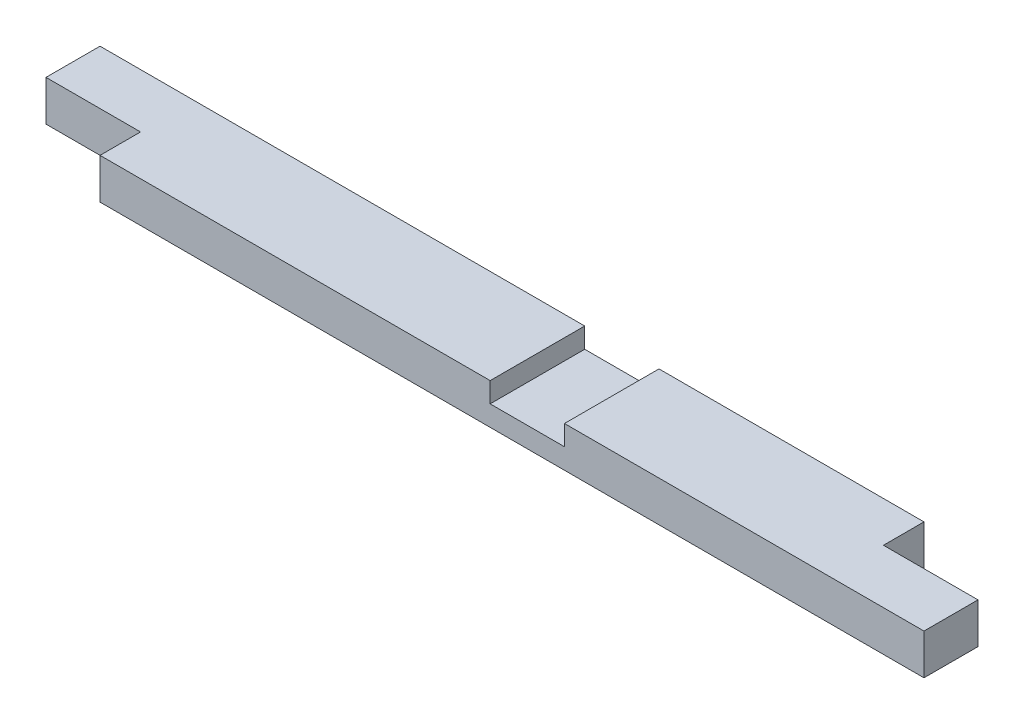
from build123d import *

# Parameters (mm, degrees)
SKETCH1_W           = 863.6
SKETCH1_H           = 88.9
BOSS_EXTRUDE1_DEPTH = 38.1
SKETCH3_W           = 88.9
SKETCH3_H           = 38.1
CUT_EXTRUDE2_DEPTH  = 39.1
SKETCH2_W           = 88.9
SKETCH2_H           = 38.1
CUT_EXTRUDE3_DEPTH  = 39.1
SKETCH4_W           = 69.85
SKETCH4_H           = 18.945503639
CUT_EXTRUDE4_DEPTH  = 89.9


with BuildPart() as part:
    # Sketch1 → Boss-Extrude1 (new body)
    with BuildSketch(Plane(origin=(0, 0, 0), x_dir=(1, 0, 0), z_dir=(0, 1, 0))):
        with Locations((431.8, 44.45)):
            Rectangle(SKETCH1_W, SKETCH1_H)
    extrude(amount=BOSS_EXTRUDE1_DEPTH)

    # Sketch3 → Cut-Extrude2 (cut, through all)
    with BuildSketch(Plane(origin=(0, 38.1, 0), x_dir=(1, 0, 0), z_dir=(0, 1, 0))):
        with Locations((44.45, 19.05)):
            Rectangle(SKETCH3_W, SKETCH3_H)
    extrude(amount=-CUT_EXTRUDE2_DEPTH, mode=Mode.SUBTRACT)

    # Sketch2 → Cut-Extrude3 (cut, through all)
    with BuildSketch(Plane.XZ):
        with Locations((819.15, -69.85)):
            Rectangle(SKETCH2_W, SKETCH2_H)
    extrude(amount=-CUT_EXTRUDE3_DEPTH, mode=Mode.SUBTRACT)

    # Sketch4 → Cut-Extrude4 (cut, through all)
    with BuildSketch(Plane(origin=(0, 0, -88.9), x_dir=(-1, 0, 0), z_dir=(0, 0, -1))):
        with Locations((-490.648634291, 28.627248181)):
            Rectangle(SKETCH4_W, SKETCH4_H)
    extrude(amount=-CUT_EXTRUDE4_DEPTH, mode=Mode.SUBTRACT)


solid = part.part
